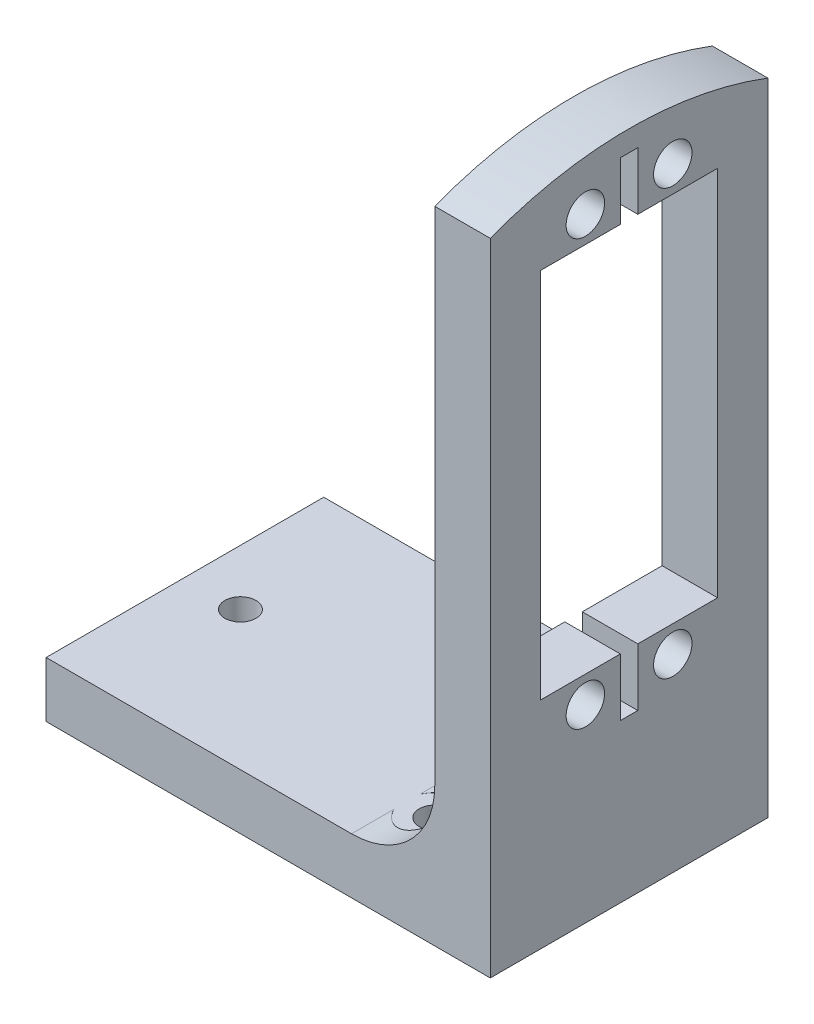
from build123d import *

# Parameters (mm, degrees)
SKETCH3_W               = 31.75
SKETCH3_H               = 73.557500078
SKETCH3_R               = 2.200000045
BOSS_EXTRUDE1_DEPTH     = 6.35
SKETCH5_W               = 31.75
SKETCH5_H               = 6.35
BOSS_EXTRUDE2_DEPTH     = 50.8
FILLET1_R               = 9.525
SKETCH6_R               = 1.777000002
CUT_EXTRUDE1_DEPTH      = 74.557500078
CUT_EXTRUDE1_DEPTH_BACK = 7.35
CUT_EXTRUDE2_DEPTH      = 51.8
SKETCH8_R               = 3.499999985
CUT_EXTRUDE3_DEPTH      = 70.85


with BuildPart() as part:
    # Sketch3 → Boss-Extrude1 (new body)
    with BuildSketch(Plane(origin=(0, 0, 0), x_dir=(0, 0, -1), z_dir=(1, 0, 0))):
        with Locations((15.875, 36.778750039)):
            Rectangle(SKETCH3_W, SKETCH3_H)
        with Locations((10.874999967, 15.285000037)):
            Circle(SKETCH3_R, mode=Mode.SUBTRACT)
        with Locations((20.875000033, 15.285000037)):
            Circle(SKETCH3_R, mode=Mode.SUBTRACT)
        with Locations((10.874999967, 63.885000119)):
            Circle(SKETCH3_R, mode=Mode.SUBTRACT)
        with Locations((20.875000033, 63.885000119)):
            Circle(SKETCH3_R, mode=Mode.SUBTRACT)
        Polygon((5.748000061, 60.857500078), (14.875, 60.857500078), (14.875, 67.461500078), (16.875, 67.461500078), (16.875, 60.857500078), (26.001999939, 60.857500078), (26.001999939, 18.312500078), (16.875, 18.312500078), (16.875, 11.708500078), (14.875, 11.708500078), (14.875, 18.312500078), (5.748000061, 18.312500078), align=None, mode=Mode.SUBTRACT)
    extrude(amount=BOSS_EXTRUDE1_DEPTH)

    # Sketch5 → Boss-Extrude2 (add)
    with BuildSketch(Plane(origin=(6.35, 0, 0), x_dir=(0, 0, -1), z_dir=(1, 0, 0))):
        with Locations((15.875, -3.175)):
            Rectangle(SKETCH5_W, SKETCH5_H)
    extrude(amount=-BOSS_EXTRUDE2_DEPTH)

    # Fillet1
    fillet1_edges = [part.edges().sort_by_distance(p)[0] for p in [
        (0, 0, -15.875),
    ]]
    fillet(fillet1_edges, radius=FILLET1_R)

    # Sketch6 → Cut-Extrude1 (cut, two sides)
    with BuildSketch(Plane(origin=(0, 0, 0), x_dir=(1, 0, 0), z_dir=(0, 1, 0))) as cut_extrude1_sk:
        with Locations((-6.35, 6.35)):
            Circle(SKETCH6_R)
        with Locations((-38.1, 15.875)):
            Circle(SKETCH6_R)
        with Locations((-6.35, 25.4)):
            Circle(SKETCH6_R)
    extrude(amount=CUT_EXTRUDE1_DEPTH, mode=Mode.SUBTRACT)
    extrude(cut_extrude1_sk.sketch, amount=-CUT_EXTRUDE1_DEPTH_BACK, mode=Mode.SUBTRACT)

    # Sketch7 → Cut-Extrude2 (cut, through all)
    with BuildSketch(Plane(origin=(6.35, 0, 0), x_dir=(0, 0, -1), z_dir=(1, 0, 0))):
        with BuildLine():
            Line((0, 66.918512437), (0, 82.748877538))
            Line((0, 82.748877538), (31.75, 82.748877538))
            Line((31.75, 82.748877538), (31.75, 66.918512437))
            ThreePointArc((31.75, 66.918512437), (15.875, 69.85), (0, 66.918512437))
        make_face()
    extrude(amount=-CUT_EXTRUDE2_DEPTH, mode=Mode.SUBTRACT)

    # Sketch8 → Cut-Extrude3 (cut, through all)
    with BuildSketch(Plane(origin=(0, 0, 0), x_dir=(1, 0, 0), z_dir=(0, 1, 0))):
        with Locations((-6.35, 25.4)):
            Circle(SKETCH8_R)
        with Locations((-6.35, 6.35)):
            Circle(SKETCH8_R)
    extrude(amount=CUT_EXTRUDE3_DEPTH, mode=Mode.SUBTRACT)


solid = part.part
